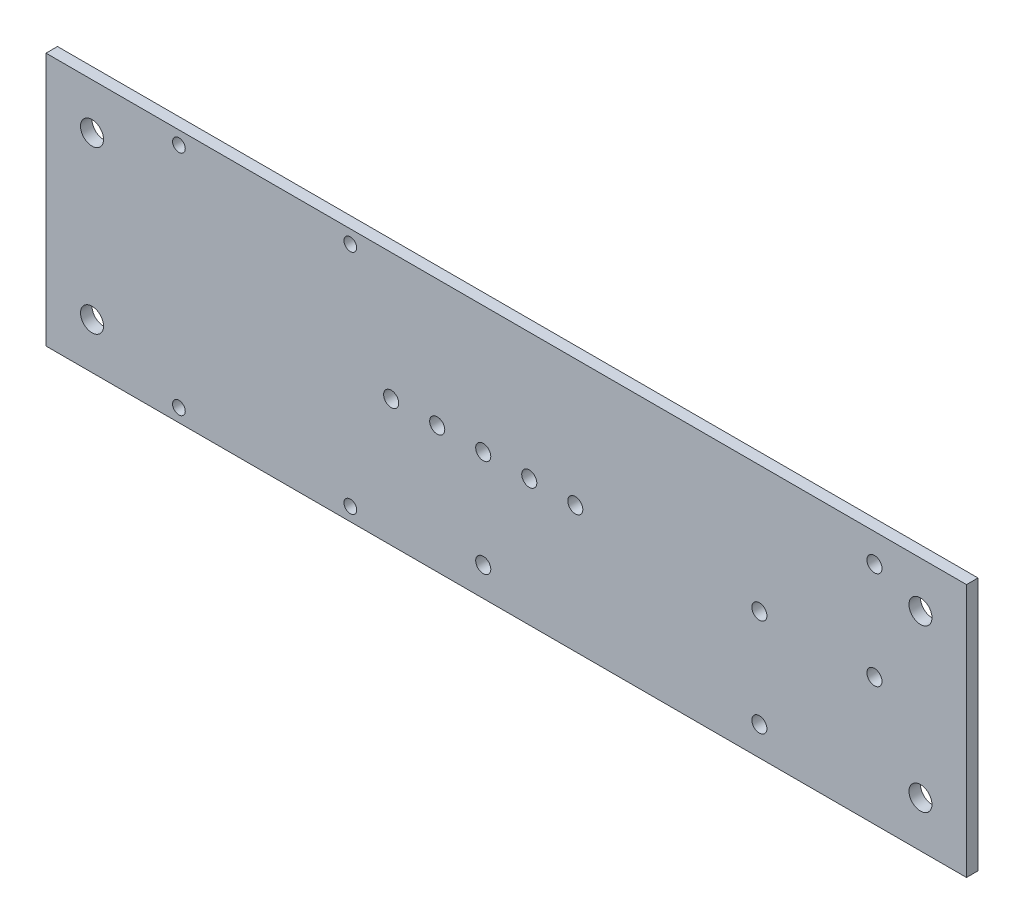
from build123d import *

# Parameters (mm, degrees)
SKETCH1_W               = 254
SKETCH1_H               = 70
BOSS_EXTRUDE1_DEPTH     = 3.175
F_8_32_TAPPED_HOLE1_D   = 4.1656
F_6_32_TAPPED_HOLE1_D   = 3.5052
F_1_4_20_TAPPED_HOLE1_D = 6.35
F_8_32_TAPPED_HOLE2_D   = 4.1656


with BuildPart() as part:
    # Sketch1 → Boss-Extrude1 (new body)
    with BuildSketch(Plane.XY):
        with Locations((127, 35)):
            Rectangle(SKETCH1_W, SKETCH1_H)
    extrude(amount=BOSS_EXTRUDE1_DEPTH)

    # #8-32 Tapped Hole1 (through all)
    with Locations(Plane.XY.offset(3.175)):
        with Locations((228.6, 62.187398), (196.85, 35), (95.25, 35), (120.65, 35), (146.05, 35), (133.35, 35), (107.95, 35)):
            Hole(F_8_32_TAPPED_HOLE1_D / 2)

    # #6-32 Tapped Hole1 (through all)
    with Locations(Plane.XY.offset(3.175)):
        with Locations((36.673632472, 66.368109228), (83.972588612, 66.324919192), (83.972588612, 3.675080808), (36.673632472, 3.631890772)):
            Hole(F_6_32_TAPPED_HOLE1_D / 2)

    # 1/4-20 Tapped Hole1 (through all)
    with Locations(Plane.XY.offset(3.175)):
        with Locations((12.7, 57.3), (241.3, 12.7), (241.3, 57.3), (12.7, 12.7)):
            Hole(F_1_4_20_TAPPED_HOLE1_D / 2)

    # #8-32 Tapped Hole2 (through all)
    with Locations(Plane.XY.offset(3.175)):
        with Locations((228.6, 35.199898), (196.85, 8.0125), (120.65, 8.0125)):
            Hole(F_8_32_TAPPED_HOLE2_D / 2)


solid = part.part
